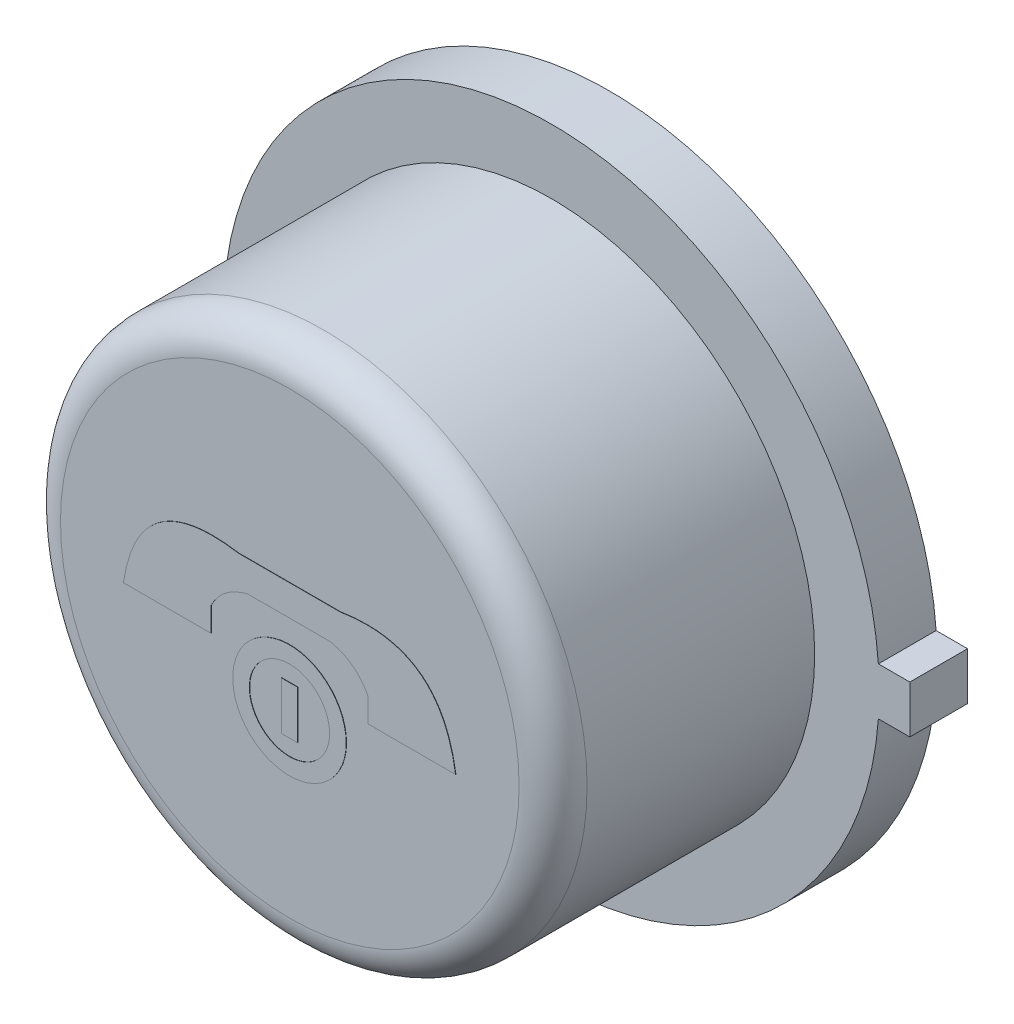
from build123d import *

# Parameters (mm, degrees)
BOSS_EXTRUDE1_DEPTH = 0.4318
SKETCH2_R           = 1.9685
BOSS_EXTRUDE2_DEPTH = 1.9558
SKETCH3_R           = 1.757566481
BOSS_EXTRUDE3_DEPTH = 0.00254
FILLET1_R           = 0.254
SKETCH4_R           = 0.424306482
SKETCH4_R_2         = 0.300017148
SKETCH4_W           = 0.121389708
SKETCH4_H           = 0.360153111
BOSS_EXTRUDE6_DEPTH = 0.00254


with BuildPart() as part:
    # Sketch1 → Boss-Extrude1 (new body)
    with BuildSketch(Plane.XY):
        with BuildLine():
            Line((2.6797, 0.1778), (2.4511, 0.1778))
            Line((2.4511, 0.1778), (2.44464279, 0.1778))
            ThreePointArc((2.44464279, 0.1778), (-2.4511, 0), (2.44464279, -0.1778))
            Line((2.44464279, -0.1778), (2.4511, -0.1778))
            Line((2.4511, -0.1778), (2.6797, -0.1778))
            Line((2.6797, -0.1778), (2.6797, 0.1778))
        make_face()
    extrude(amount=BOSS_EXTRUDE1_DEPTH)

    # Sketch2 → Boss-Extrude2 (add)
    with BuildSketch(Plane.XY.offset(0.4318)):
        Circle(SKETCH2_R)
    extrude(amount=BOSS_EXTRUDE2_DEPTH)

    # Sketch3 → Boss-Extrude3 (add)
    with BuildSketch(Plane(origin=(0, 0, 0), x_dir=(-1, 0, 0), z_dir=(0, 0, -1))):
        Circle(SKETCH3_R)
    extrude(amount=BOSS_EXTRUDE3_DEPTH)

    # Fillet1
    fillet1_edges = [part.edges().sort_by_distance(p)[0] for p in [
        (-1.9685, 0, 2.3876),
    ]]
    fillet(fillet1_edges, radius=FILLET1_R)

    # Sketch4 → Boss-Extrude6 (add)
    with BuildSketch(Plane.XY.offset(2.3876)):
        with Locations((0, -0.366036865)):
            Circle(SKETCH4_R)
        with Locations((0, -0.366036865)):
            Circle(SKETCH4_R_2, mode=Mode.SUBTRACT)
        with Locations((0, -0.366036865)):
            Rectangle(SKETCH4_W, SKETCH4_H)
        with BuildLine():
            add(Edge.make_bspline(
                [(0.586204822, 0.021051911), (0.500696389, 0.187631338), (0.309059488, 0.231300095)],
                knots=[0, 0, 0, 1, 1, 1], degree=2))
            Line((0.309059488, 0.231300095), (-0.309059488, 0.231300095))
            add(Edge.make_bspline(
                [(-0.586204822, 0.021051911), (-0.500696389, 0.187631338), (-0.309059488, 0.231300095)],
                knots=[0, 0, 0, 1, 1, 1], degree=2))
            Line((-0.586204822, 0.021051911), (-0.586204822, -0.160526067))
            Line((-0.586204822, -0.160526067), (-1.241971444, -0.160526067))
            add(Edge.make_bspline(
                [(-1.241971444, -0.160526067), (-1.130990503, 0.580439961), (-0.379571619, 0.460661751)],
                knots=[0, 0, 0, 1, 1, 1], degree=2))
            Line((-0.379571619, 0.460661751), (0.379571619, 0.460661751))
            add(Edge.make_bspline(
                [(1.241971444, -0.160526067), (1.130990503, 0.580439961), (0.379571619, 0.460661751)],
                knots=[0, 0, 0, 1, 1, 1], degree=2))
            Line((1.241971444, -0.160526067), (0.586204822, -0.160526067))
            Line((0.586204822, -0.160526067), (0.586204822, 0.021051911))
        make_face()
    extrude(amount=BOSS_EXTRUDE6_DEPTH)


solid = part.part
